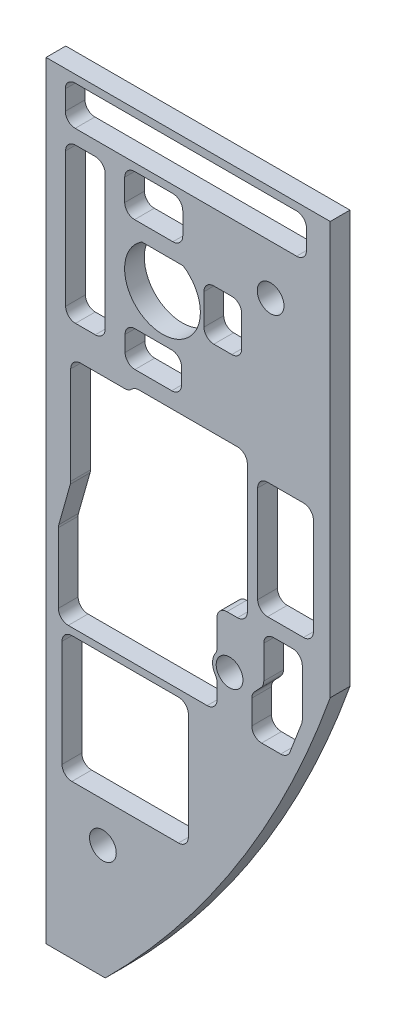
from build123d import *

# Parameters (mm, degrees)
SKETCH1_R             = 1.190050877
BOSS_EXTRUDE1_DEPTH   = 3.175
CUT_EXTRUDE1_DEPTH    = 4.175
SKETCH12_W            = 19.05
SKETCH12_H            = 23.8125
CUT_EXTRUDE2_DEPTH    = 4.175
SKETCH17_W            = 20.32
SKETCH17_H            = 20.32
CUT_EXTRUDE3_DEPTH    = 4.175
FILLET1_R             = 1.5875
F_6_CLEARANCE_HOLE1_D = 4.3053
CUT_EXTRUDE4_DEPTH    = 4.175
FILLET3_R             = 1.5875


with BuildPart() as part:
    # Sketch1 → Boss-Extrude1 (new body)
    with BuildSketch(Plane.XY):
        with BuildLine():
            Line((0, -17.78), (0, -141.2875))
            Line((0, -141.2875), (9.525, -141.2875))
            ThreePointArc((9.525, -141.2875), (30.833523511, -114.746148224), (45.72, -84.1375))
            Line((45.72, -84.1375), (45.72, -17.78))
            Line((45.72, -17.78), (0, -17.78))
        make_face()
        with Locations((18.7325, -40.894)):
            Circle(SKETCH1_R, mode=Mode.SUBTRACT)
    extrude(amount=-BOSS_EXTRUDE1_DEPTH)

    # Sketch11 → Cut-Extrude1 (cut, through all)
    with BuildSketch(Plane(origin=(20.844780046, -43.574770805, 0), x_dir=(1, 0, 0), z_dir=(0, 0, 1))):
        with BuildLine():
            Line((-5.443361979, 7.786170805), (1.218801886, 7.786170805))
            ThreePointArc((1.218801886, 7.786170805), (-2.112280046, -3.415229195), (-5.443361979, 7.786170805))
        make_face()
    extrude(amount=-CUT_EXTRUDE1_DEPTH, mode=Mode.SUBTRACT)

    # Sketch12 → Cut-Extrude2 (cut, through all)
    with BuildSketch(Plane.XY):
        with Locations((22.86, -68.54825)):
            Rectangle(SKETCH12_W, SKETCH12_H)
    extrude(amount=-CUT_EXTRUDE2_DEPTH, mode=Mode.SUBTRACT)

    # Sketch17 → Cut-Extrude3 (cut, through all)
    with BuildSketch(Plane.XY):
        with Locations((12.731722108, -106.422544949)):
            Rectangle(SKETCH17_W, SKETCH17_H)
    extrude(amount=-CUT_EXTRUDE3_DEPTH, mode=Mode.SUBTRACT)

    # Fillet1
    fillet1_edges = [part.edges().sort_by_distance(p)[0] for p in [
        (13.335, -80.4545, -1.5875),
        (13.335, -56.642, -1.5875),
        (32.385, -56.642, -1.5875),
        (32.385, -80.4545, -1.5875),
        (22.891722108, -96.262544949, -1.5875),
        (22.891722108, -116.582544949, -1.5875),
        (2.571722108, -116.582544949, -1.5875),
        (2.571722108, -96.262544949, -1.5875),
    ]]
    fillet(fillet1_edges, radius=FILLET1_R)

    # #6 Clearance Hole1 (through all)
    with Locations(Plane.XY):
        with Locations((9.144, -122.9995), (29.5275, -88.7095), (36.1315, -33.274)):
            Hole(F_6_CLEARANCE_HOLE1_D / 2)

    # Sketch20 → Cut-Extrude4 (cut, through all)
    with BuildSketch(Plane.XY):
        with BuildLine():
            Line((1.9875505, -93.544142926), (1.9875505, -82.303444681))
            ThreePointArc((1.9875505, -82.303444681), (2.002594465, -82.085411961), (2.04744123, -81.871511621))
            Line((2.04744123, -81.871511621), (3.907011168, -75.294806703))
            ThreePointArc((3.907011168, -75.294806703), (3.951857933, -75.080906363), (3.966901898, -74.862873644))
            Line((3.966901898, -74.862873644), (3.966901898, -59.18890883))
            ThreePointArc((3.966901898, -59.18890883), (4.431869883, -58.066376815), (5.554401898, -57.60140883))
            Line((5.554401898, -57.60140883), (9.117080567, -57.60140883))
            Line((9.117080567, -57.60140883), (27.511016487, -57.60140883))
            Line((27.511016487, -57.60140883), (27.511016487, -86.314118515))
            ThreePointArc((27.511016487, -86.314118515), (27.442924116, -86.774071456), (27.244488351, -87.194567028))
            ThreePointArc((27.244488351, -87.194567028), (26.786216014, -88.708422955), (27.244488351, -90.222278881))
            ThreePointArc((27.244488351, -90.222278881), (27.442924116, -90.642774454), (27.511016487, -91.102727395))
            Line((27.511016487, -91.102727395), (27.511016487, -93.544142926))
            ThreePointArc((27.511016487, -93.544142926), (27.046048502, -94.666674941), (25.923516487, -95.131642926))
            Line((25.923516487, -95.131642926), (3.5750505, -95.131642926))
            ThreePointArc((3.5750505, -95.131642926), (2.452518485, -94.666674941), (1.9875505, -93.544142926))
        make_face()
        with BuildLine():
            Line((39.239705373, -94.952090373), (41.119480948, -90.066805962))
            ThreePointArc((41.119480948, -90.066805962), (41.19867933, -89.78663398), (41.225378141, -89.49671003))
            Line((41.225378141, -89.49671003), (41.225378141, -81.903016886))
            ThreePointArc((41.225378141, -81.903016886), (40.760410156, -80.780484871), (39.637878141, -80.315516886))
            Line((39.637878141, -80.315516886), (36.61477648, -80.315516886))
            ThreePointArc((36.61477648, -80.315516886), (35.492244465, -80.780484871), (35.02727648, -81.903016886))
            Line((35.02727648, -81.903016886), (35.02727648, -87.180260326))
            ThreePointArc((35.02727648, -87.180260326), (34.917248136, -87.760978637), (34.602415054, -88.261198713))
            Line((34.602415054, -88.261198713), (33.520520126, -89.424866126))
            ThreePointArc((33.520520126, -89.424866126), (33.205687045, -89.925086202), (33.095658701, -90.505804513))
            Line((33.095658701, -90.505804513), (33.095658701, -94.381994441))
            ThreePointArc((33.095658701, -94.381994441), (33.560626686, -95.504526456), (34.683158701, -95.969494441))
            Line((34.683158701, -95.969494441), (37.758102566, -95.969494441))
            ThreePointArc((37.758102566, -95.969494441), (38.65674848, -95.690654737), (39.239705373, -94.952090373))
        make_face()
        with BuildLine():
            Line((20.217000424, -54.116093897), (14.306430977, -54.116093897))
            ThreePointArc((14.306430977, -54.116093897), (13.183898962, -53.651125912), (12.718930977, -52.528593897))
            Line((12.718930977, -52.528593897), (12.718930977, -50.013735278))
            ThreePointArc((12.718930977, -50.013735278), (13.183898962, -48.891203263), (14.306430977, -48.426235278))
            Line((14.306430977, -48.426235278), (20.217000424, -48.426235278))
            ThreePointArc((20.217000424, -48.426235278), (21.339532439, -48.891203263), (21.804500424, -50.013735278))
            Line((21.804500424, -50.013735278), (21.804500424, -52.528593897))
            ThreePointArc((21.804500424, -52.528593897), (21.339532439, -53.651125912), (20.217000424, -54.116093897))
        make_face()
        with BuildLine():
            Line((29.885101261, -44.237571754), (26.996152875, -44.237571754))
            ThreePointArc((26.996152875, -44.237571754), (25.87362086, -43.772603769), (25.408652875, -42.650071754))
            Line((25.408652875, -42.650071754), (25.408652875, -37.714249524))
            ThreePointArc((25.408652875, -37.714249524), (25.87362086, -36.591717509), (26.996152875, -36.126749524))
            Line((26.996152875, -36.126749524), (29.885101261, -36.126749524))
            ThreePointArc((29.885101261, -36.126749524), (31.007633276, -36.591717509), (31.472601261, -37.714249524))
            Line((31.472601261, -37.714249524), (31.472601261, -42.650071754))
            ThreePointArc((31.472601261, -42.650071754), (31.007633276, -43.772603769), (29.885101261, -44.237571754))
        make_face()
        with BuildLine():
            Line((20.406928746, -33.259078247), (14.243980141, -33.259078247))
            ThreePointArc((14.243980141, -33.259078247), (13.121448126, -32.794110262), (12.656480141, -31.671578247))
            Line((12.656480141, -31.671578247), (12.656480141, -28.136425111))
            ThreePointArc((12.656480141, -28.136425111), (13.121448126, -27.013893096), (14.243980141, -26.548925111))
            Line((14.243980141, -26.548925111), (20.406928746, -26.548925111))
            ThreePointArc((20.406928746, -26.548925111), (21.529460761, -27.013893096), (21.994428746, -28.136425111))
            Line((21.994428746, -28.136425111), (21.994428746, -31.671578247))
            ThreePointArc((21.994428746, -31.671578247), (21.529460761, -32.794110262), (20.406928746, -33.259078247))
        make_face()
        with BuildLine():
            Line((9.51166577, -50.881662937), (9.51166577, -29.220981566))
            ThreePointArc((9.51166577, -29.220981566), (9.046697786, -28.098449551), (7.92416577, -27.633481566))
            Line((7.92416577, -27.633481566), (4.736850702, -27.633481566))
            ThreePointArc((4.736850702, -27.633481566), (3.614318687, -28.098449551), (3.149350702, -29.220981566))
            Line((3.149350702, -29.220981566), (3.149350702, -50.881662937))
            ThreePointArc((3.149350702, -50.881662937), (3.614318687, -52.004194952), (4.736850702, -52.469162937))
            Line((4.736850702, -52.469162937), (7.92416577, -52.469162937))
            ThreePointArc((7.92416577, -52.469162937), (9.046697786, -52.004194952), (9.51166577, -50.881662937))
        make_face()
        with BuildLine():
            Line((40.313091041, -25.321573057), (4.684667753, -25.321573057))
            ThreePointArc((4.684667753, -25.321573057), (3.562135738, -24.856605072), (3.097167753, -23.734073057))
            Line((3.097167753, -23.734073057), (3.097167753, -20.606442704))
            ThreePointArc((3.097167753, -20.606442704), (3.562135738, -19.483910688), (4.684667753, -19.018942704))
            Line((4.684667753, -19.018942704), (40.313091041, -19.018942704))
            ThreePointArc((40.313091041, -19.018942704), (41.435623056, -19.483910688), (41.900591041, -20.606442704))
            Line((41.900591041, -20.606442704), (41.900591041, -23.734073057))
            ThreePointArc((41.900591041, -23.734073057), (41.435623056, -24.856605072), (40.313091041, -25.321573057))
        make_face()
        with BuildLine():
            Line((43.01404737, -76.302416551), (43.01404737, -60.74025149))
            ThreePointArc((43.01404737, -60.74025149), (42.549079385, -59.617719475), (41.42654737, -59.15275149))
            Line((41.42654737, -59.15275149), (35.637827713, -59.15275149))
            ThreePointArc((35.637827713, -59.15275149), (34.515295697, -59.617719475), (34.050327713, -60.74025149))
            Line((34.050327713, -60.74025149), (34.050327713, -76.302416551))
            ThreePointArc((34.050327713, -76.302416551), (34.515295697, -77.424948566), (35.637827713, -77.889916551))
            Line((35.637827713, -77.889916551), (41.42654737, -77.889916551))
            ThreePointArc((41.42654737, -77.889916551), (42.549079385, -77.424948566), (43.01404737, -76.302416551))
        make_face()
    extrude(amount=-CUT_EXTRUDE4_DEPTH, mode=Mode.SUBTRACT)

    # Fillet3
    fillet3_edges = [part.edges().sort_by_distance(p)[0] for p in [
        (13.464536443, -57.60140883, -1.5875),
        (27.511016487, -80.4545, -1.5875),
    ]]
    fillet(fillet3_edges, radius=FILLET3_R)


solid = part.part
